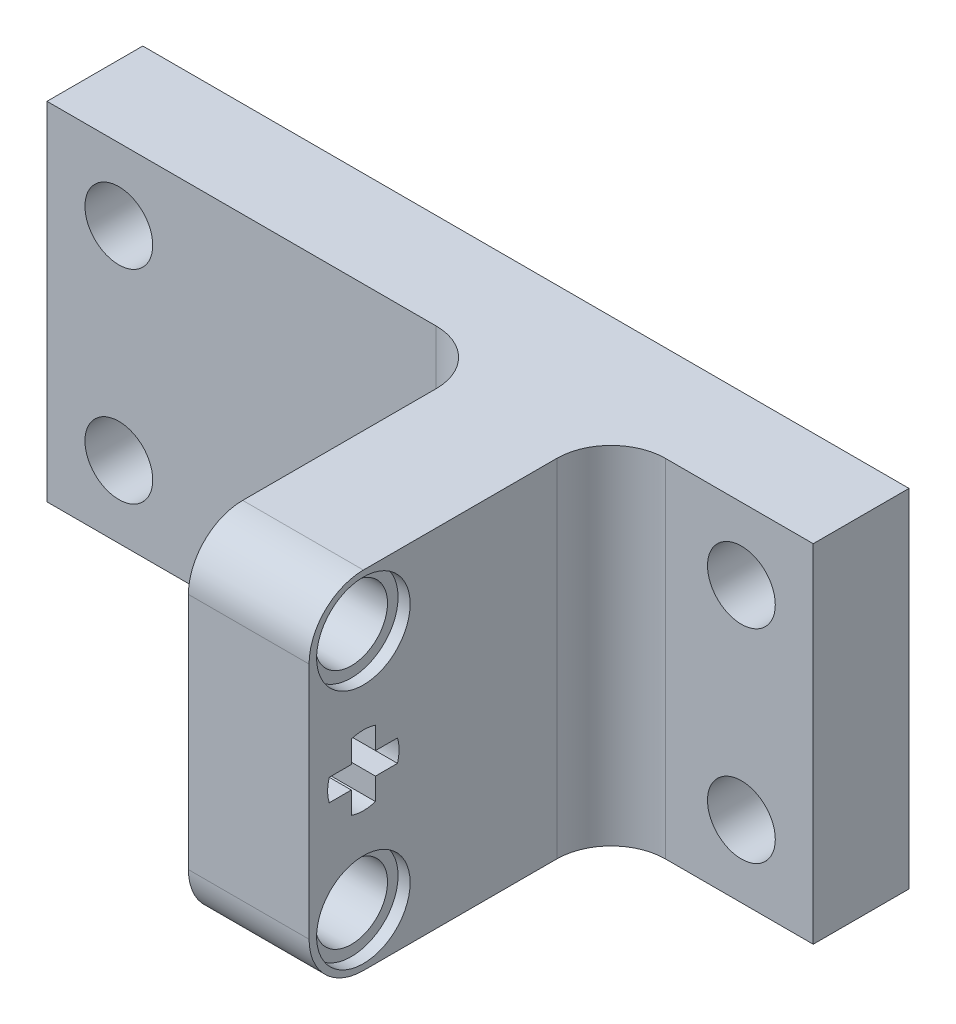
from build123d import *

# Parameters (mm, degrees)
BOSS_EXTRUDE1_DEPTH   = 11.5
SKETCH3_R             = 2.4
CUT_EXTRUDE1_DEPTH    = 46.489009619
SKETCH3_3_R           = 3.1
SKETCH3_3_R_2         = 2.4
CUT_EXTRUDE2_DEPTH    = 0.8
FILLET1_R             = 3.6
F_8_CLEARANCE_HOLE1_D = 4.4958


with BuildPart() as part:
    # Sketch2 → Boss-Extrude1 (new, symmetric)
    with BuildSketch(Plane(origin=(0, 0, 0), x_dir=(1, 0, 0), z_dir=(0, 1, 0))):
        Polygon((4, -3.175), (4, -19.599999916), (4, -23.199999916), (12, -23.199999916), (12, -19.599999916), (12, -3.175), (25.4, -3.175), (25.4, 3.175), (-25.4, 3.175), (-25.4, -3.175), align=None)
    extrude(amount=BOSS_EXTRUDE1_DEPTH, both=True)

    # Sketch3 → Cut-Extrude1 (cut, through all)
    with BuildSketch(Plane(origin=(12, 0, 0), x_dir=(0, 0, -1), z_dir=(1, 0, 0))):
        with BuildLine():
            Line((-20.399999916, 2.19411255), (-20.399999916, 0.73137085))
            Line((-20.399999916, 0.73137085), (-21.862741616, 0.73137085))
            ThreePointArc((-21.862741616, 0.73137085), (-21.967727251, 0), (-21.862741616, -0.73137085))
            Line((-21.862741616, -0.73137085), (-20.399999916, -0.73137085))
            Line((-20.399999916, -0.73137085), (-20.399999916, -2.19411255))
            ThreePointArc((-20.399999916, -2.19411255), (-19.599999916, -2.320249175), (-18.799999916, -2.19411255))
            Line((-18.799999916, -2.19411255), (-18.799999916, -0.73137085))
            Line((-18.799999916, -0.73137085), (-17.337258216, -0.73137085))
            ThreePointArc((-17.337258216, -0.73137085), (-17.232272581, 0), (-17.337258216, 0.73137085))
            Line((-17.337258216, 0.73137085), (-18.799999916, 0.73137085))
            Line((-18.799999916, 0.73137085), (-18.799999916, 2.19411255))
            ThreePointArc((-18.799999916, 2.19411255), (-19.599999916, 2.320249175), (-20.399999916, 2.19411255))
        make_face()
        with Locations((-19.599999916, 8)):
            Circle(SKETCH3_R)
        with Locations((-19.599999916, -8)):
            Circle(SKETCH3_R)
    extrude(amount=-CUT_EXTRUDE1_DEPTH, mode=Mode.SUBTRACT)

    # Sketch3_3 → Cut-Extrude2 (cut)
    # profile 1 of 2: a face of its own
    with BuildSketch(Plane(origin=(12, 0, 0), x_dir=(0, 0, -1), z_dir=(1, 0, 0))):
        with Locations((-19.599999916, 8)):
            Circle(SKETCH3_3_R)
        with Locations((-19.599999916, 8)):
            Circle(SKETCH3_3_R_2, mode=Mode.SUBTRACT)
    # profile 2 of 2: a face of its own
    with BuildSketch(Plane(origin=(12, 0, 0), x_dir=(0, 0, -1), z_dir=(1, 0, 0))):
        with Locations((-19.599999916, -8)):
            Circle(SKETCH3_3_R)
        with Locations((-19.599999916, -8)):
            Circle(SKETCH3_3_R_2, mode=Mode.SUBTRACT)
    cut_extrude2 = extrude(amount=-CUT_EXTRUDE2_DEPTH, mode=Mode.SUBTRACT)

    # Mirror1: Cut-Extrude2 across plane
    add(cut_extrude2.mirror(Plane(origin=(8, 0, 0), x_dir=(0, 0, 1), z_dir=(1, 0, 0))), mode=Mode.SUBTRACT)

    # Fillet1
    fillet1_edges = [part.edges().sort_by_distance(p)[0] for p in [
        (8, -11.5, 23.199999916),
        (8, 11.5, 23.199999916),
        (4, 0, 3.175),
        (12, 0, 3.175),
    ]]
    fillet(fillet1_edges, radius=FILLET1_R)

    # 8 Clearance Hole1 (through all)
    with Locations(Plane.XY.offset(3.175)):
        with Locations((-20.6375, 6.7375), (-20.6375, -6.7375), (20.6375, -6.7375), (20.6375, 6.7375)):
            Hole(F_8_CLEARANCE_HOLE1_D / 2)


solid = part.part
